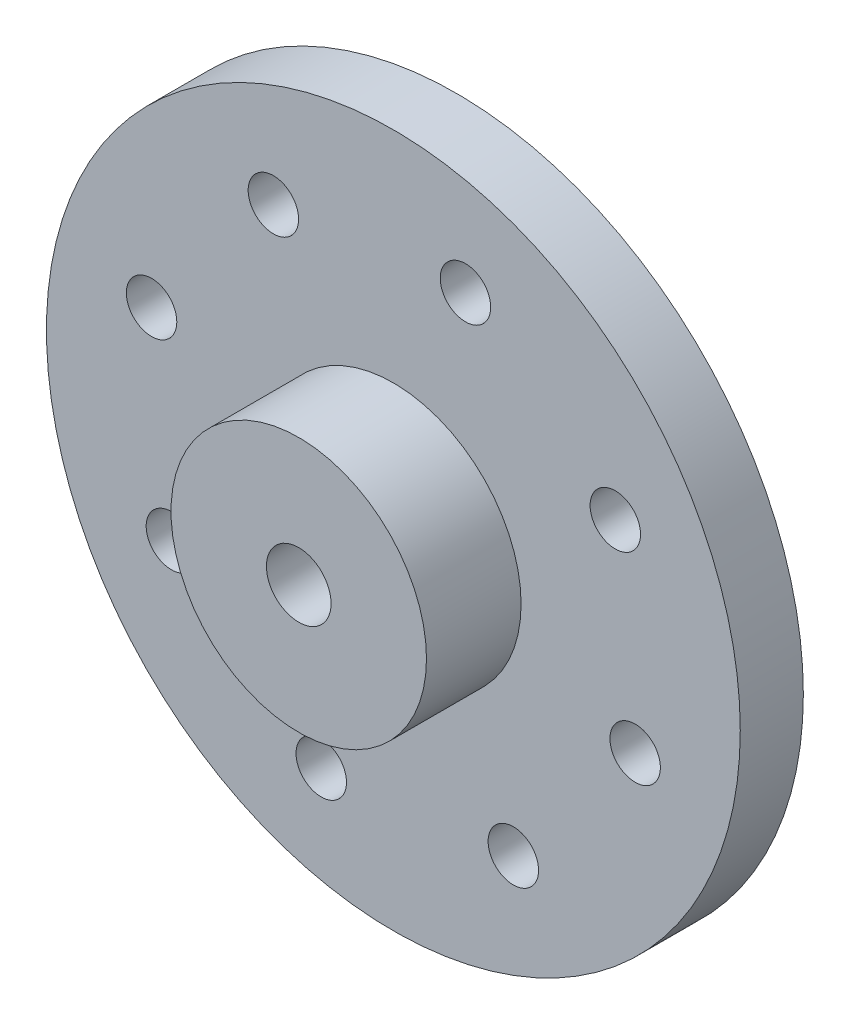
from build123d import *

# Parameters (mm, degrees)
SKETCH1_R               = 11
SKETCH1_R_2             = 2.669858215
BOSS_EXTRUDE1_DEPTH     = 2
SKETCH2_R               = 4.05
BOSS_EXTRUDE2_DEPTH     = 3
SKETCH3_R               = 4
SKETCH3_R_2             = 2.669858215
BOSS_EXTRUDE3_DEPTH     = 1
CHAMFER1_SIZE           = 0.6
M2_TAPPED_HOLE1_D       = 1.6
M2_5_TAPPED_HOLE1_D     = 2.05
M2_5_TAPPED_HOLE1_DEPTH = 6.35
M2_5_TAPPED_HOLE1_TIP   = 0.615882135


with BuildPart() as part:
    # Sketch1 → Boss-Extrude1 (new body)
    with BuildSketch(Plane.XY):
        Circle(SKETCH1_R)
        Circle(SKETCH1_R_2, mode=Mode.SUBTRACT)
    extrude(amount=BOSS_EXTRUDE1_DEPTH)

    # Sketch2 → Boss-Extrude2 (add)
    with BuildSketch(Plane.XY.offset(2)):
        Circle(SKETCH2_R)
    extrude(amount=BOSS_EXTRUDE2_DEPTH)

    # Sketch3 → Boss-Extrude3 (add)
    with BuildSketch(Plane(origin=(0, 0, 0), x_dir=(-1, 0, 0), z_dir=(0, 0, -1))):
        Circle(SKETCH3_R)
        Circle(SKETCH3_R_2, mode=Mode.SUBTRACT)
    extrude(amount=BOSS_EXTRUDE3_DEPTH)

    # Chamfer1
    chamfer1_edges = [part.edges().sort_by_distance(p)[0] for p in [
        (4, 0, -1),
    ]]
    chamfer(chamfer1_edges, length=CHAMFER1_SIZE)

    # M2 Tapped Hole1 (through all)
    with Locations(Plane.XY.offset(2)):
        with Locations((2.286188648, 7.666377336), (7.037526898, 3.804367906), (7.666377336, -2.286188648), (3.804367906, -7.037526898), (-2.286188648, -7.666377336), (-7.037526898, -3.804367906), (-7.666377336, 2.286188648), (-3.804367906, 7.037526898)):
            Hole(M2_TAPPED_HOLE1_D / 2)

    # M2.5 Tapped Hole1
    with Locations(Plane.XY.offset(5)):
        with Locations((0, 0)):
            Hole(M2_5_TAPPED_HOLE1_D / 2, depth=M2_5_TAPPED_HOLE1_DEPTH)
            with Locations((0, 0, -(M2_5_TAPPED_HOLE1_DEPTH + M2_5_TAPPED_HOLE1_TIP / 2))):  # 118° drill point
                Cone(0, M2_5_TAPPED_HOLE1_D / 2, M2_5_TAPPED_HOLE1_TIP, mode=Mode.SUBTRACT)


solid = part.part
